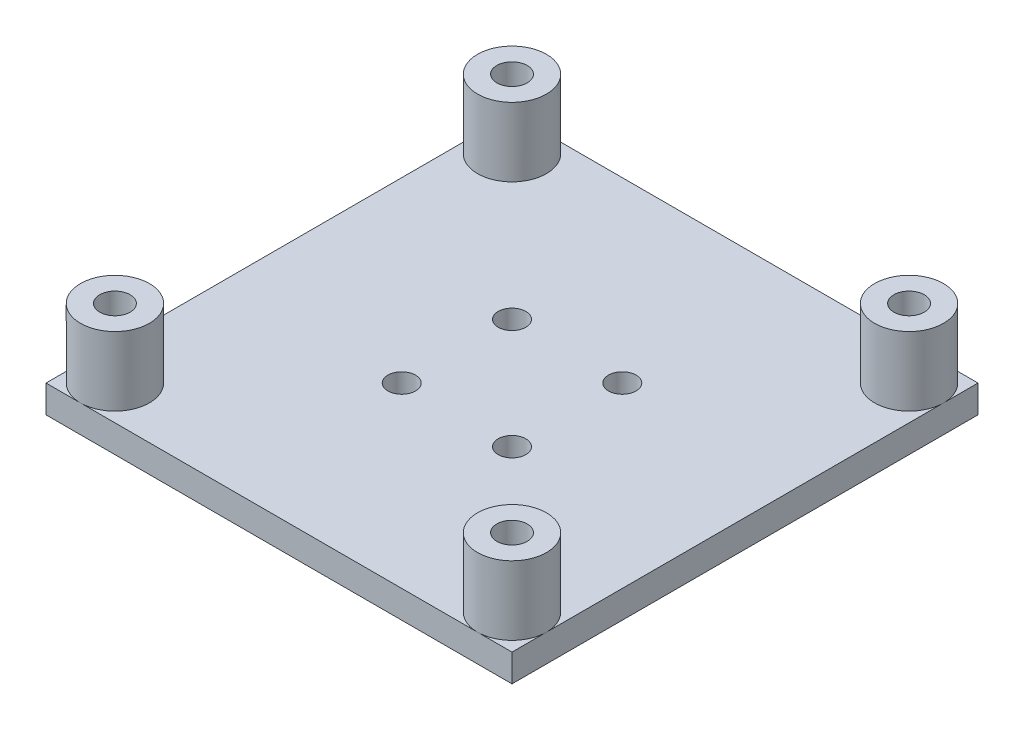
from build123d import *

# Parameters (mm, degrees)
SKETCH1_W           = 42.926
SKETCH1_H           = 42.926
SKETCH1_R           = 1.397
BOSS_EXTRUDE1_DEPTH = 2.54
SKETCH2_R           = 3.175
SKETCH2_R_2         = 1.397
BOSS_EXTRUDE2_DEPTH = 6.35
SKETCH3_R           = 3.175
SKETCH3_R_2         = 1.27
BOSS_EXTRUDE3_DEPTH = 6.35
SKETCH4_R           = 1.27
CUT_EXTRUDE1_DEPTH  = 9.89


with BuildPart() as part:
    # Sketch1 → Boss-Extrude1 (new body)
    with BuildSketch(Plane(origin=(0, 0, 0), x_dir=(1, 0, 0), z_dir=(0, 1, 0))):
        with Locations((-27.382131523, -2.193417639)):
            Rectangle(SKETCH1_W, SKETCH1_H)
        with Locations((-45.670131523, 16.094582361)):
            Circle(SKETCH1_R, mode=Mode.SUBTRACT)
        with Locations((-9.094131523, 16.094582361)):
            Circle(SKETCH1_R, mode=Mode.SUBTRACT)
        with Locations((-45.670131523, -20.481417639)):
            Circle(SKETCH1_R, mode=Mode.SUBTRACT)
        with Locations((-9.094131523, -20.481417639)):
            Circle(SKETCH1_R, mode=Mode.SUBTRACT)
    extrude(amount=BOSS_EXTRUDE1_DEPTH)

    # Sketch2 → Boss-Extrude2 (add)
    with BuildSketch(Plane(origin=(0, 2.54, 0), x_dir=(1, 0, 0), z_dir=(0, 1, 0))):
        with Locations((-45.670131523, 16.094582361)):
            Circle(SKETCH2_R)
        with Locations((-45.670131523, 16.094582361)):
            Circle(SKETCH2_R_2, mode=Mode.SUBTRACT)
        with Locations((-9.094131523, 16.094582361)):
            Circle(SKETCH2_R)
        with Locations((-9.094131523, 16.094582361)):
            Circle(SKETCH2_R_2, mode=Mode.SUBTRACT)
        with Locations((-9.094131523, -20.481417639)):
            Circle(SKETCH2_R)
        with Locations((-9.094131523, -20.481417639)):
            Circle(SKETCH2_R_2, mode=Mode.SUBTRACT)
        with Locations((-45.670131523, -20.481417639)):
            Circle(SKETCH2_R)
        with Locations((-45.670131523, -20.481417639)):
            Circle(SKETCH2_R_2, mode=Mode.SUBTRACT)
    extrude(amount=BOSS_EXTRUDE2_DEPTH)

    # Sketch3 → Boss-Extrude3 (add)
    with BuildSketch(Plane.XZ):
        with Locations((-32.462131523, 7.273417639)):
            Circle(SKETCH3_R)
        with Locations((-32.462131523, 7.273417639)):
            Circle(SKETCH3_R_2, mode=Mode.SUBTRACT)
        with Locations((-22.302131523, 7.273417639)):
            Circle(SKETCH3_R)
        with Locations((-22.302131523, 7.273417639)):
            Circle(SKETCH3_R_2, mode=Mode.SUBTRACT)
        with Locations((-22.302131523, -2.886582361)):
            Circle(SKETCH3_R)
        with Locations((-22.302131523, -2.886582361)):
            Circle(SKETCH3_R_2, mode=Mode.SUBTRACT)
        with Locations((-32.462131523, -2.886582361)):
            Circle(SKETCH3_R)
        with Locations((-32.462131523, -2.886582361)):
            Circle(SKETCH3_R_2, mode=Mode.SUBTRACT)
    extrude(amount=BOSS_EXTRUDE3_DEPTH)

    # Sketch4 → Cut-Extrude1 (cut, through all)
    with BuildSketch(Plane.XZ):
        with Locations((-32.462131523, -2.886582361)):
            Circle(SKETCH4_R)
        with Locations((-32.462131523, 7.273417639)):
            Circle(SKETCH4_R)
        with Locations((-22.302131523, -2.886582361)):
            Circle(SKETCH4_R)
        with Locations((-22.302131523, 7.273417639)):
            Circle(SKETCH4_R)
    extrude(amount=-CUT_EXTRUDE1_DEPTH, mode=Mode.SUBTRACT)


solid = part.part
